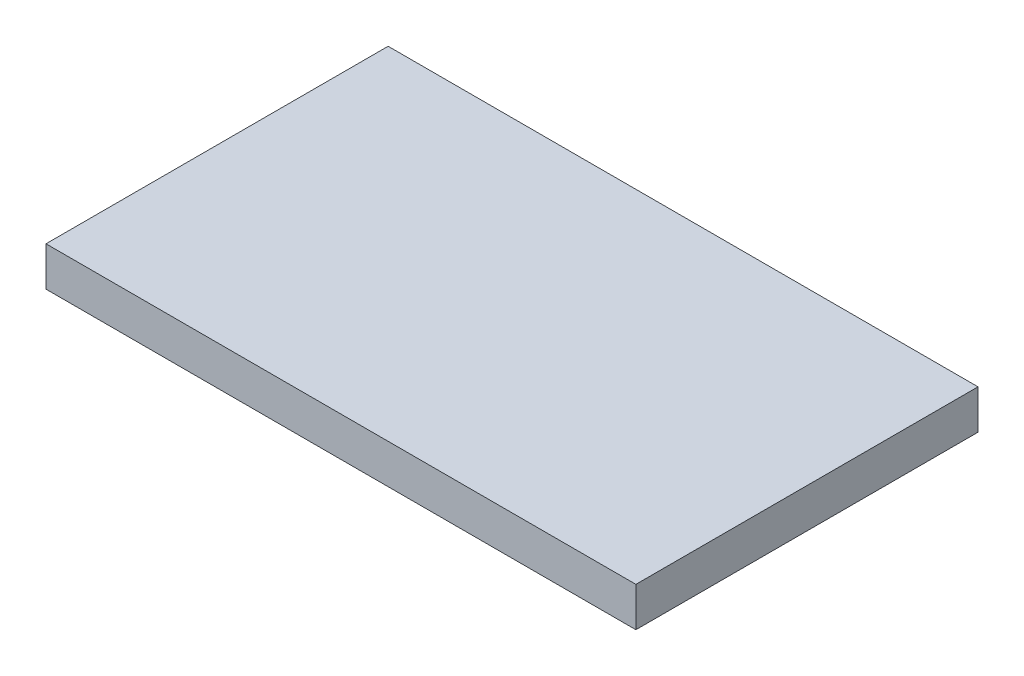
from build123d import *

# Parameters (mm, degrees)
SKETCH1_W           = 38.1
SKETCH1_H           = 22.098
BOSS_EXTRUDE1_DEPTH = 2.54


with BuildPart() as part:
    # Sketch1 → Boss-Extrude1 (new body)
    with BuildSketch(Plane(origin=(0, 0, 0), x_dir=(1, 0, 0), z_dir=(0, 1, 0))):
        with Locations((19.05, 11.049)):
            Rectangle(SKETCH1_W, SKETCH1_H)
    extrude(amount=BOSS_EXTRUDE1_DEPTH)


solid = part.part
